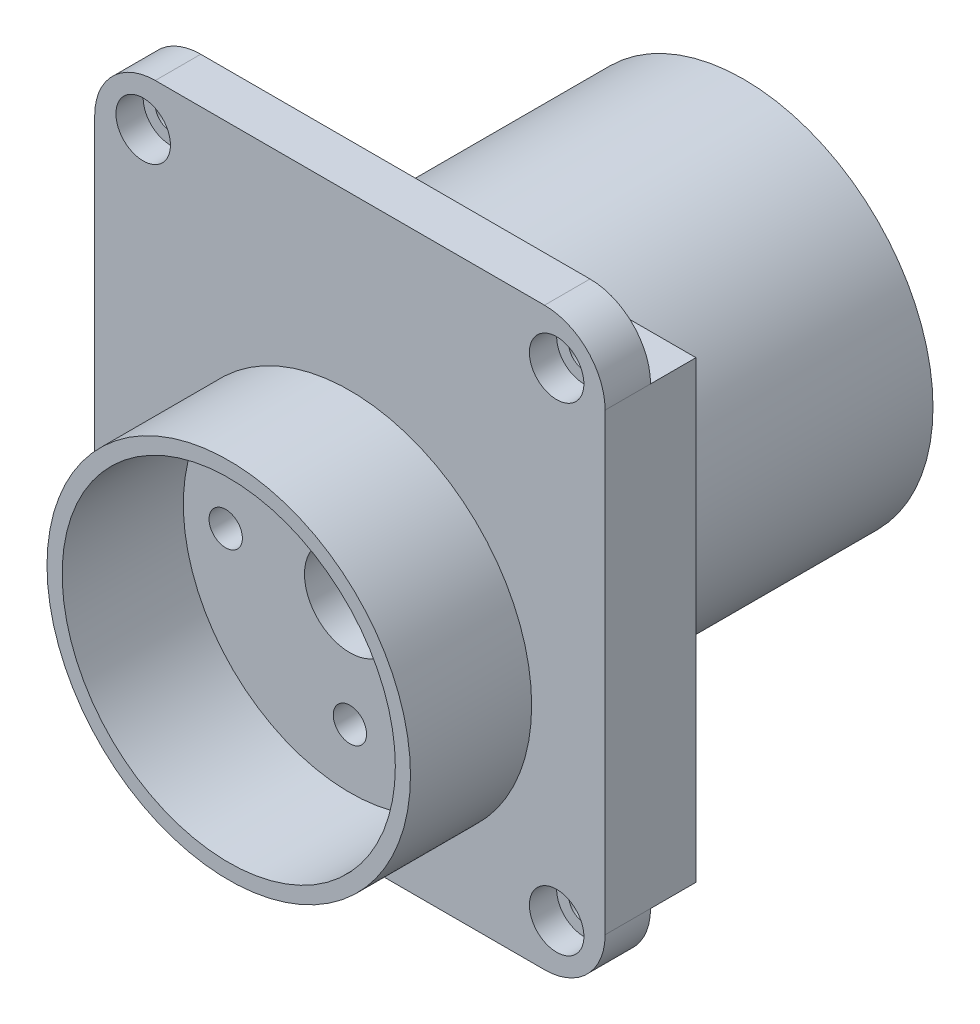
from build123d import *

# Parameters (mm, degrees)
SZKIC1_R                    = 3
SZKIC1_R_2                  = 1.1
SZKIC1_R_3                  = 1
DODANIE_WYCI_GNI_CIE1_DEPTH = 3
SZKIC2_R                    = 12
SZKIC2_R_2                  = 11
DODANIE_WYCI_GNI_CIE2_DEPTH = 8
SZKIC3_R                    = 1.1
SZKIC3_R_2                  = 3
WYTNIJ_WYCI_GNI_CIE1_DEPTH  = 1
SZKIC4_R                    = 1.8
WYTNIJ_WYCI_GNI_CIE2_DEPTH  = 1.8
ZAOKR_GLENIE1_R             = 4
SKETCH1_W                   = 33.7
SKETCH1_H                   = 30
BOSS_EXTRUDE1_DEPTH         = 3
SKETCH2_R                   = 12.5
SKETCH2_R_2                 = 10.5
BOSS_EXTRUDE2_DEPTH         = 20


with BuildPart() as part:
    # Szkic1 → Dodanie-wyciągnięcie1 (new body)
    with BuildSketch(Plane.XY):
        Polygon((-16.85, 0), (-16.85, -14.7), (0, -14.7), (16.85, -14.7), (16.85, 23.3), (-16.85, 23.3), align=None)
        Circle(SZKIC1_R, mode=Mode.SUBTRACT)
        with Locations((-8.2, 0)):
            Circle(SZKIC1_R_2, mode=Mode.SUBTRACT)
        with Locations((8.2, 0)):
            Circle(SZKIC1_R_2, mode=Mode.SUBTRACT)
        with Locations((0, 7.1)):
            Circle(SZKIC1_R_2, mode=Mode.SUBTRACT)
        with Locations((0, -7.1)):
            Circle(SZKIC1_R_2, mode=Mode.SUBTRACT)
        with Locations((-13.65, 20.1)):
            Circle(SZKIC1_R_3, mode=Mode.SUBTRACT)
        with Locations((13.65, 20.1)):
            Circle(SZKIC1_R_3, mode=Mode.SUBTRACT)
        with Locations((13.65, -11.5)):
            Circle(SZKIC1_R_3, mode=Mode.SUBTRACT)
        with Locations((-13.65, -11.5)):
            Circle(SZKIC1_R_3, mode=Mode.SUBTRACT)
    extrude(amount=DODANIE_WYCI_GNI_CIE1_DEPTH)

    # Szkic2 → Dodanie-wyciągnięcie2 (add)
    with BuildSketch(Plane.XY.offset(3)):
        Circle(SZKIC2_R)
        Circle(SZKIC2_R_2, mode=Mode.SUBTRACT)
    extrude(amount=DODANIE_WYCI_GNI_CIE2_DEPTH)

    # Szkic3 → Wytnij-wyciągnięcie1 (cut)
    with BuildSketch(Plane(origin=(0, 0, 0), x_dir=(-1, 0, 0), z_dir=(0, 0, -1))):
        with BuildLine():
            Line((11.326209992, 22.3), (-11.326209992, 22.3))
            ThreePointArc((-11.326209992, 22.3), (-10.67711184, 21.284033778), (-10.45, 20.1))
            ThreePointArc((-10.45, 20.1), (-12.385088936, 17.160612309), (-15.85, 17.776209992))
            Line((-15.85, 17.776209992), (-15.85, -9.176209992))
            ThreePointArc((-15.85, -9.176209992), (-12.385088936, -8.560612309), (-10.45, -11.5))
            ThreePointArc((-10.45, -11.5), (-10.67711184, -12.684033778), (-11.326209992, -13.7))
            Line((-11.326209992, -13.7), (11.326209992, -13.7))
            ThreePointArc((11.326209992, -13.7), (11.3872583, -9.2372583), (15.85, -9.176209992))
            Line((15.85, -9.176209992), (15.85, 17.776209992))
            ThreePointArc((15.85, 17.776209992), (11.3872583, 17.8372583), (11.326209992, 22.3))
        make_face()
        with Locations((-8.2, 0)):
            Circle(SZKIC3_R, mode=Mode.SUBTRACT)
        with Locations((0, -7.1)):
            Circle(SZKIC3_R, mode=Mode.SUBTRACT)
        Circle(SZKIC3_R_2, mode=Mode.SUBTRACT)
        with Locations((8.2, 0)):
            Circle(SZKIC3_R, mode=Mode.SUBTRACT)
        with Locations((0, 7.1)):
            Circle(SZKIC3_R, mode=Mode.SUBTRACT)
    extrude(amount=-WYTNIJ_WYCI_GNI_CIE1_DEPTH, mode=Mode.SUBTRACT)

    # Szkic4 → Wytnij-wyciągnięcie2 (cut)
    with BuildSketch(Plane.XY.offset(3)):
        with Locations((-13.65, 20.1)):
            Circle(SZKIC4_R)
        with Locations((13.65, 20.1)):
            Circle(SZKIC4_R)
        with Locations((13.65, -11.5)):
            Circle(SZKIC4_R)
        with Locations((-13.65, -11.5)):
            Circle(SZKIC4_R)
    extrude(amount=-WYTNIJ_WYCI_GNI_CIE2_DEPTH, mode=Mode.SUBTRACT)

    # Zaokrąglenie1
    zaokr_glenie1_edges = [part.edges().sort_by_distance(p)[0] for p in [
        (-16.85, 23.3, 1.5),
        (16.85, 23.3, 1.5),
        (16.85, -14.7, 1.5),
        (-16.85, -14.7, 1.5),
    ]]
    fillet(zaokr_glenie1_edges, radius=ZAOKR_GLENIE1_R)

    # Sketch1 → Boss-Extrude1 (add)
    with BuildSketch(Plane(origin=(0, 0, 0), x_dir=(-1, 0, 0), z_dir=(0, 0, -1))):
        with Locations((0, 4.3)):
            Rectangle(SKETCH1_W, SKETCH1_H)
    extrude(amount=BOSS_EXTRUDE1_DEPTH)

    # Sketch2 → Boss-Extrude2 (add)
    with BuildSketch(Plane(origin=(0, 0, -3), x_dir=(-1, 0, 0), z_dir=(0, 0, -1))):
        with Locations((0, 4.3)):
            Circle(SKETCH2_R)
        with Locations((0, 4.3)):
            Circle(SKETCH2_R_2, mode=Mode.SUBTRACT)
    extrude(amount=BOSS_EXTRUDE2_DEPTH)


solid = part.part
